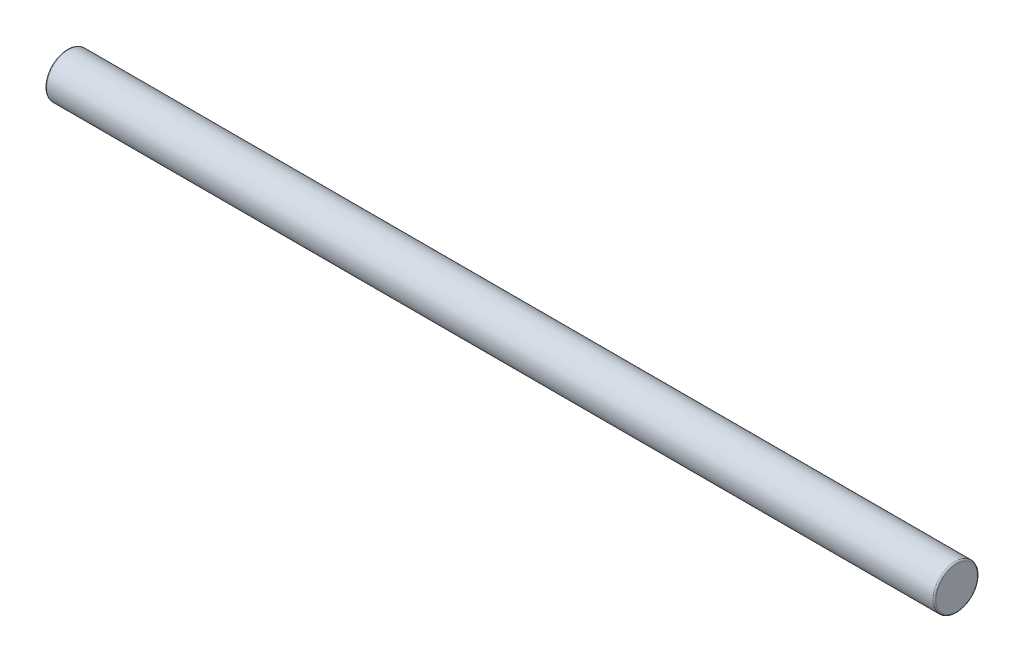
from build123d import *

# Parameters (mm, degrees)
SKETCH1_R      = 0.381
EXTRUDE1_DEPTH = 15.24
FILLET1_R      = 0.0254


with BuildPart() as part:
    # Sketch1 → Extrude1 (new body)
    with BuildSketch(Plane(origin=(0, 0, 0), x_dir=(0, 0, -1), z_dir=(1, 0, 0))):
        Circle(SKETCH1_R)
    extrude(amount=EXTRUDE1_DEPTH)

    # Fillet1
    fillet1_edges = [part.edges().sort_by_distance(p)[0] for p in [
        (0, 0, 0.381),
        (15.24, 0, 0.381),
    ]]
    fillet(fillet1_edges, radius=FILLET1_R)


solid = part.part
